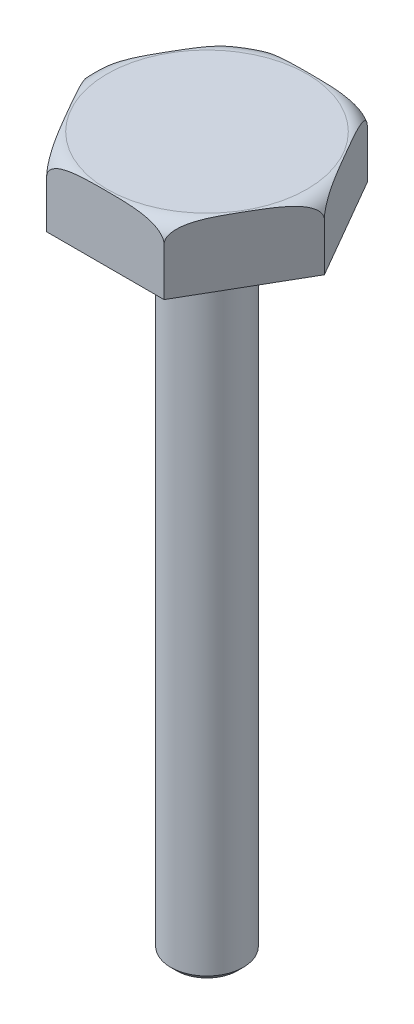
from build123d import *

# Parameters (mm, degrees)
BOSS_EXTRUDE1_DEPTH = 45
SKETCH3_R           = 25
BOSS_EXTRUDE2_DEPTH = 445
CHAMFER1_SIZE       = 4


with BuildPart() as part:
    # Sketch2 → Boss-Extrude1 (new body)
    with BuildSketch(Plane(origin=(0, 0, 0), x_dir=(1, 0, 0), z_dir=(0, 1, 0))):
        Polygon((80.829037687, 0), (40.414518843, 70), (-40.414518843, 70), (-80.829037687, 0), (-40.414518843, -70), (40.414518843, -70), align=None)
    extrude(amount=BOSS_EXTRUDE1_DEPTH)

    # Sketch3 → Boss-Extrude2 (add)
    with BuildSketch(Plane(origin=(0, 0, 0), x_dir=(1, 0, 0), z_dir=(0, 1, 0))):
        Circle(SKETCH3_R)
    extrude(amount=-BOSS_EXTRUDE2_DEPTH)

    # Sketch4 → Cut-Revolve1 (revolve, cut)
    with BuildSketch(Plane.XY):
        with BuildLine():
            Line((80.829037687, 33), (80.829037687, 45))
            Line((80.829037687, 45), (68.829037687, 45))
            ThreePointArc((68.829037687, 45), (77.314319061, 41.485281374), (80.829037687, 33))
        make_face()
    revolve(axis=Axis((0, 0, 0), (0, 1, 0)), mode=Mode.SUBTRACT)

    # Chamfer1
    chamfer1_edges = [part.edges().sort_by_distance(p)[0] for p in [
        (-25, -445, 0),
    ]]
    chamfer(chamfer1_edges, length=CHAMFER1_SIZE)


solid = part.part
